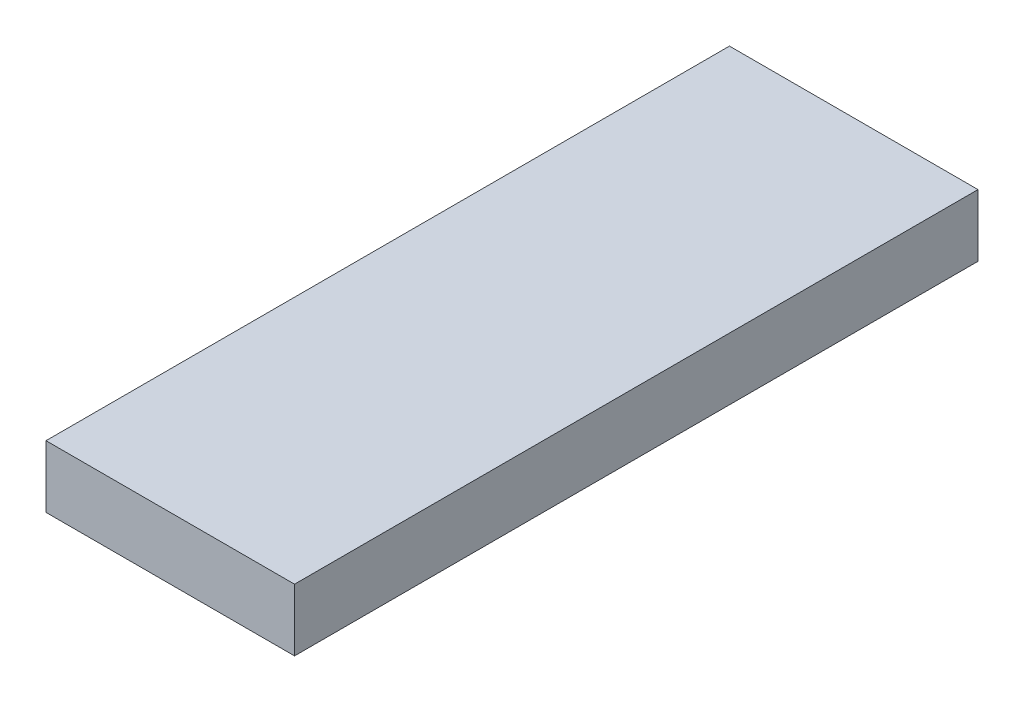
from build123d import *

# Parameters (mm, degrees)
SKETCH1_W           = 40
SKETCH1_H           = 110
BOSS_EXTRUDE1_DEPTH = 10


with BuildPart() as part:
    # Sketch1 → Boss-Extrude1 (new body)
    with BuildSketch(Plane(origin=(0, 0, 0), x_dir=(1, 0, 0), z_dir=(0, 1, 0))):
        Rectangle(SKETCH1_W, SKETCH1_H)
    extrude(amount=BOSS_EXTRUDE1_DEPTH)


solid = part.part
